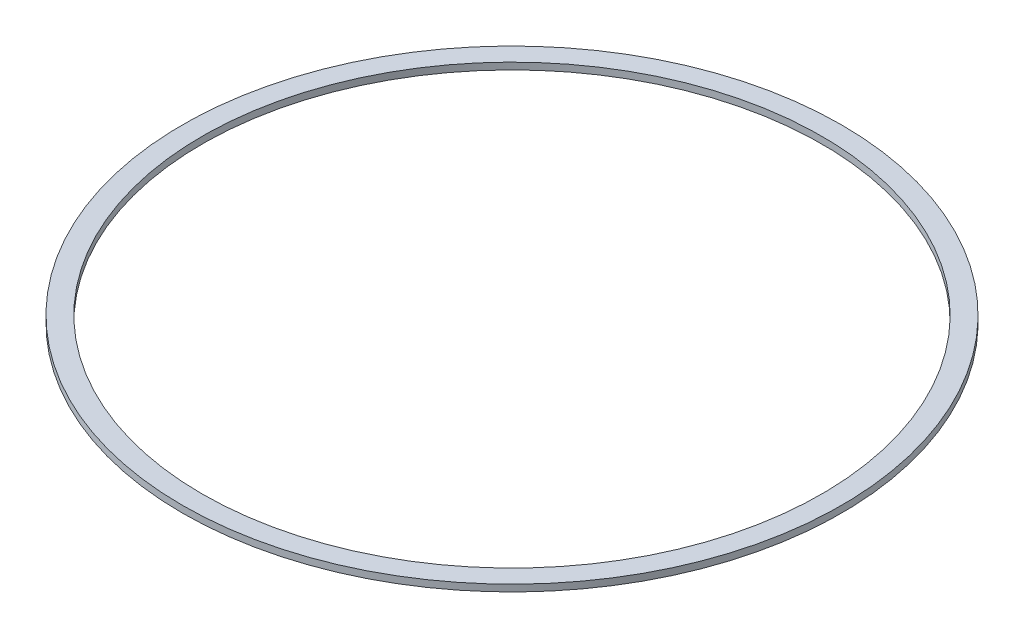
from build123d import *

# Parameters (mm, degrees)
SKETCH_1_R      = 29.25
SKETCH_1_R_2    = 27.5
EXTRUDE_1_DEPTH = 0.6


with BuildPart() as part:
    # Эскиз1 → Бобышка-Вытянуть1 (new body)
    with BuildSketch(Plane(origin=(0, 0, 0), x_dir=(1, 0, 0), z_dir=(0, 1, 0))):
        Circle(SKETCH_1_R)
        Circle(SKETCH_1_R_2, mode=Mode.SUBTRACT)
    extrude(amount=EXTRUDE_1_DEPTH)


solid = part.part
